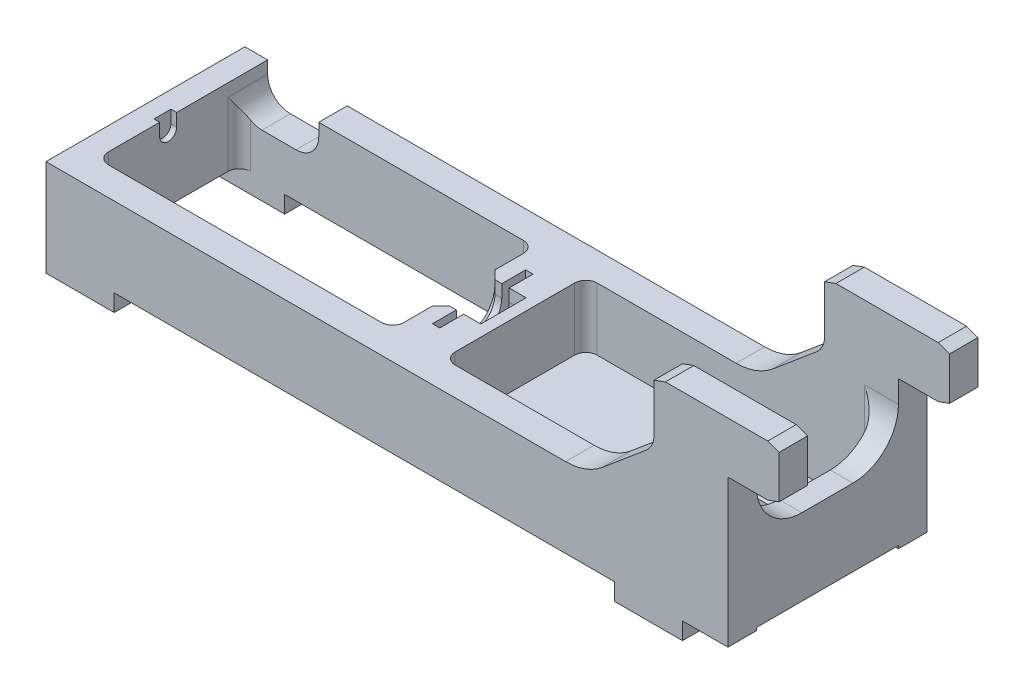
from build123d import *

# Parameters (mm, degrees)
SKETCH1_W           = 60
SKETCH1_H           = 7
BOSS_EXTRUDE1_DEPTH = 8.75
SKETCH2_W           = 26
SKETCH2_H           = 12.5
CUT_EXTRUDE1_DEPTH  = 8
SKETCH4_W           = 4
SKETCH4_H           = 1.1
CUT_EXTRUDE2_DEPTH  = 3.5
SKETCH5_W           = 8.2
SKETCH5_H           = 1.1
CUT_EXTRUDE4_DEPTH  = 0.65
SKETCH6_W           = 1.5
SKETCH6_H           = 1.1
CUT_EXTRUDE5_DEPTH  = 0.5
BOSS_EXTRUDE2_DEPTH = 2.5
SKETCH9_W           = 6
SKETCH9_H           = 2.5
BOSS_EXTRUDE4_DEPTH = 1.5
SKETCH10_W          = 25.5
SKETCH10_H          = 12.5
CUT_EXTRUDE6_DEPTH  = 5.5
CUT_EXTRUDE7_DEPTH  = 4
SKETCH12_W          = 60
SKETCH12_H          = 12.5
CUT_EXTRUDE8_DEPTH  = 0.25
FILLET1_R           = 4
FILLET2_R           = 5
FILLET3_R           = 1
CUT_EXTRUDE9_DEPTH  = 10
FILLET4_R           = 2
CHAMFER1_SIZE       = 0.75


with BuildPart() as part:
    # Sketch1 → Boss-Extrude1 (new body, symmetric)
    with BuildSketch(Plane.XY):
        with Locations((30, 3.5)):
            Rectangle(SKETCH1_W, SKETCH1_H)
    extrude(amount=BOSS_EXTRUDE1_DEPTH, both=True)

    # Sketch2 → Cut-Extrude1 (cut, through all)
    with BuildSketch(Plane(origin=(0, 7, 0), x_dir=(1, 0, 0), z_dir=(0, 1, 0))):
        with Locations((15, 0)):
            Rectangle(SKETCH2_W, SKETCH2_H)
    extrude(amount=-CUT_EXTRUDE1_DEPTH, mode=Mode.SUBTRACT)

    # Sketch3 → Cut-Revolve5 (revolve, cut)
    with BuildSketch(Plane.XY):
        Polygon((1.5, 5.9), (1.5, 5.15), (28, 5.15), (28, 3.9), (29.35, 3.9), (29.35, 1.8), (30, 1.8), (30, 3.9), (31.5, 3.9), (31.5, 5.9), align=None)
    revolve(axis=Axis((0, 5.9, 0), (1, 0, 0)), mode=Mode.SUBTRACT)

    # Sketch4 → Cut-Extrude2 (cut)
    with BuildSketch(Plane.ZY.offset(-28)):
        with Locations((0, 6.45)):
            Rectangle(SKETCH4_W, SKETCH4_H)
    extrude(amount=-CUT_EXTRUDE2_DEPTH, mode=Mode.SUBTRACT)

    # Sketch5 → Cut-Extrude4 (cut)
    with BuildSketch(Plane(origin=(29.35, 0, 0), x_dir=(0, 0, -1), z_dir=(1, 0, 0))):
        with Locations((0, 6.45)):
            Rectangle(SKETCH5_W, SKETCH5_H)
    extrude(amount=CUT_EXTRUDE4_DEPTH, mode=Mode.SUBTRACT)

    # Sketch6 → Cut-Extrude5 (cut)
    with BuildSketch(Plane(origin=(2, 0, 0), x_dir=(0, 0, -1), z_dir=(1, 0, 0))):
        with Locations((0, 6.45)):
            Rectangle(SKETCH6_W, SKETCH6_H)
    extrude(amount=-CUT_EXTRUDE5_DEPTH, mode=Mode.SUBTRACT)

    # Sketch7 → Boss-Extrude2 (add)
    with BuildSketch(Plane.XY.offset(8.75)):
        Polygon((54.5, 17.4625), (53.5, 17.098529766), (53.5, 12), (47.541232037, 7), (60, 7), (60, 12.9625), (63.5, 12.9625), (64.5, 13.326470234), (64.5, 17.098529766), (63.5, 17.4625), align=None)
    boss_extrude2 = extrude(amount=-BOSS_EXTRUDE2_DEPTH)

    # Sketch9 → Boss-Extrude4 (add)
    with BuildSketch(Plane.XZ):
        with Locations((3, 7.5)):
            Rectangle(SKETCH9_W, SKETCH9_H)
        with Locations((53, 7.5)):
            Rectangle(SKETCH9_W, SKETCH9_H)
    boss_extrude4 = extrude(amount=BOSS_EXTRUDE4_DEPTH)

    # Mirror1: Boss-Extrude2, Boss-Extrude4 across plane
    add(boss_extrude2.mirror(Plane.XY))
    add(boss_extrude4.mirror(Plane.XY))

    # Sketch10 → Cut-Extrude6 (cut)
    with BuildSketch(Plane(origin=(0, 7, 0), x_dir=(1, 0, 0), z_dir=(0, 1, 0))):
        with Locations((45.25, 0)):
            Rectangle(SKETCH10_W, SKETCH10_H)
    extrude(amount=-CUT_EXTRUDE6_DEPTH, mode=Mode.SUBTRACT)

    # Sketch11 → Cut-Extrude7 (cut, through all)
    with BuildSketch(Plane(origin=(0, 1.5, 0), x_dir=(1, 0, 0), z_dir=(0, 1, 0))):
        with BuildLine():
            Line((52.35, -2.38125), (48.35, -2.38125))
            ThreePointArc((48.35, -2.38125), (45.96875, 0), (48.35, 2.38125))
            Line((48.35, 2.38125), (52.35, 2.38125))
            ThreePointArc((52.35, 2.38125), (54.73125, 0), (52.35, -2.38125))
        make_face()
    extrude(amount=-CUT_EXTRUDE7_DEPTH, mode=Mode.SUBTRACT)

    # Sketch12 → Cut-Extrude8 (cut)
    with BuildSketch(Plane.XZ):
        with Locations((30, 0)):
            Rectangle(SKETCH12_W, SKETCH12_H)
    extrude(amount=-CUT_EXTRUDE8_DEPTH, mode=Mode.SUBTRACT)

    # Fillet1
    fillet1_edges = [part.edges().sort_by_distance(p)[0] for p in [
        (59, 7, -6.25),
        (59, 7, 6.25),
    ]]
    fillet(fillet1_edges, radius=FILLET1_R)

    # Fillet2
    fillet2_edges = [part.edges().sort_by_distance(p)[0] for p in [
        (47.541232037, 7, 7.5),
        (47.541232037, 7, -7.5),
    ]]
    fillet(fillet2_edges, radius=FILLET2_R)

    # Fillet3
    fillet3_edges = [part.edges().sort_by_distance(p)[0] for p in [
        (58, 4.25, -6.25),
        (58, 4.25, 6.25),
        (32.5, 4.25, 6.25),
        (32.5, 4.25, -6.25),
        (28, 3.625, 6.25),
        (2, 3.625, 6.25),
        (28, 3.625, -6.25),
        (2, 3.625, -6.25),
    ]]
    fillet(fillet3_edges, radius=FILLET3_R)

    # Sketch13 → Cut-Extrude9 (cut)
    with BuildSketch(Plane(origin=(0, 0, -8.75), x_dir=(-1, 0, 0), z_dir=(0, 0, -1))):
        with BuildLine():
            Line((-2, 7), (-2, 5.9))
            ThreePointArc((-2, 5.9), (-2.585786438, 4.485786438), (-4, 3.9))
            Line((-4, 3.9), (-7, 3.9))
            ThreePointArc((-7, 3.9), (-8.414213562, 4.485786438), (-9, 5.9))
            Line((-9, 5.9), (-9, 7))
            Line((-9, 7), (-2, 7))
        make_face()
    extrude(amount=-CUT_EXTRUDE9_DEPTH, mode=Mode.SUBTRACT)

    # Fillet4
    fillet4_edges = [part.edges().sort_by_distance(p)[0] for p in [
        (53.5, 12, -7.5),
        (53.5, 12, 7.5),
    ]]
    fillet(fillet4_edges, radius=FILLET4_R)

    # Chamfer1
    chamfer1_edges = [part.edges().sort_by_distance(p)[0] for p in [
        (28, 3.9, 0),
        (28, 6.45, 2),
        (28, 6.45, -2),
    ]]
    chamfer(chamfer1_edges, length=CHAMFER1_SIZE)


solid = part.part
